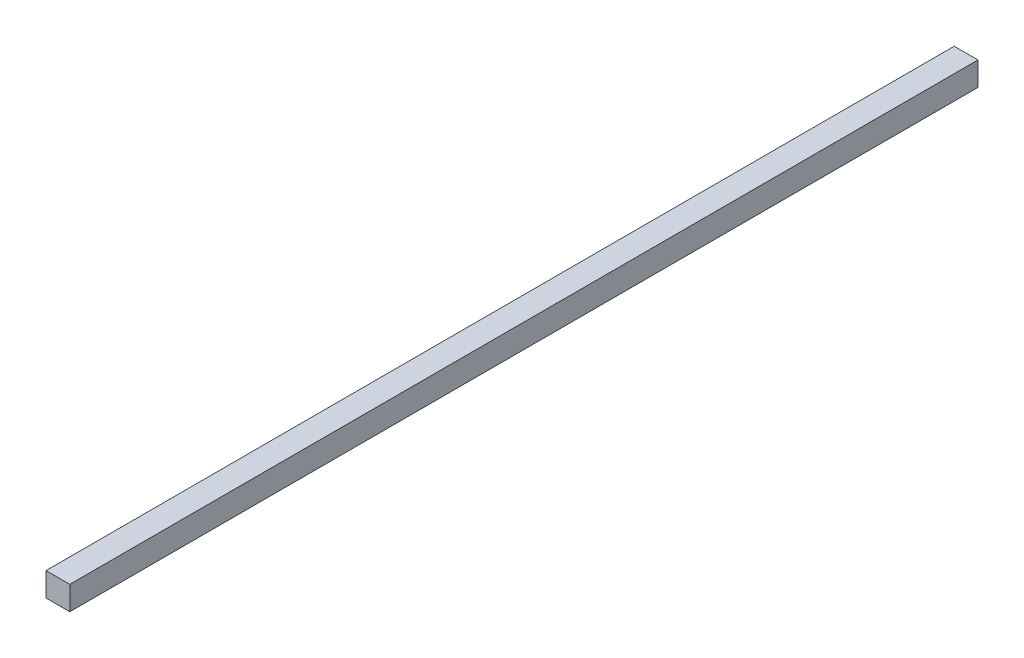
from build123d import *

# Parameters (mm, degrees)
SKETCH1_W           = 20
SKETCH1_H           = 20
BOSS_EXTRUDE1_DEPTH = 382


with BuildPart() as part:
    # Sketch1 → Boss-Extrude1 (new body, symmetric)
    with BuildSketch(Plane.XY):
        Rectangle(SKETCH1_W, SKETCH1_H)
    extrude(amount=BOSS_EXTRUDE1_DEPTH, both=True)


solid = part.part
